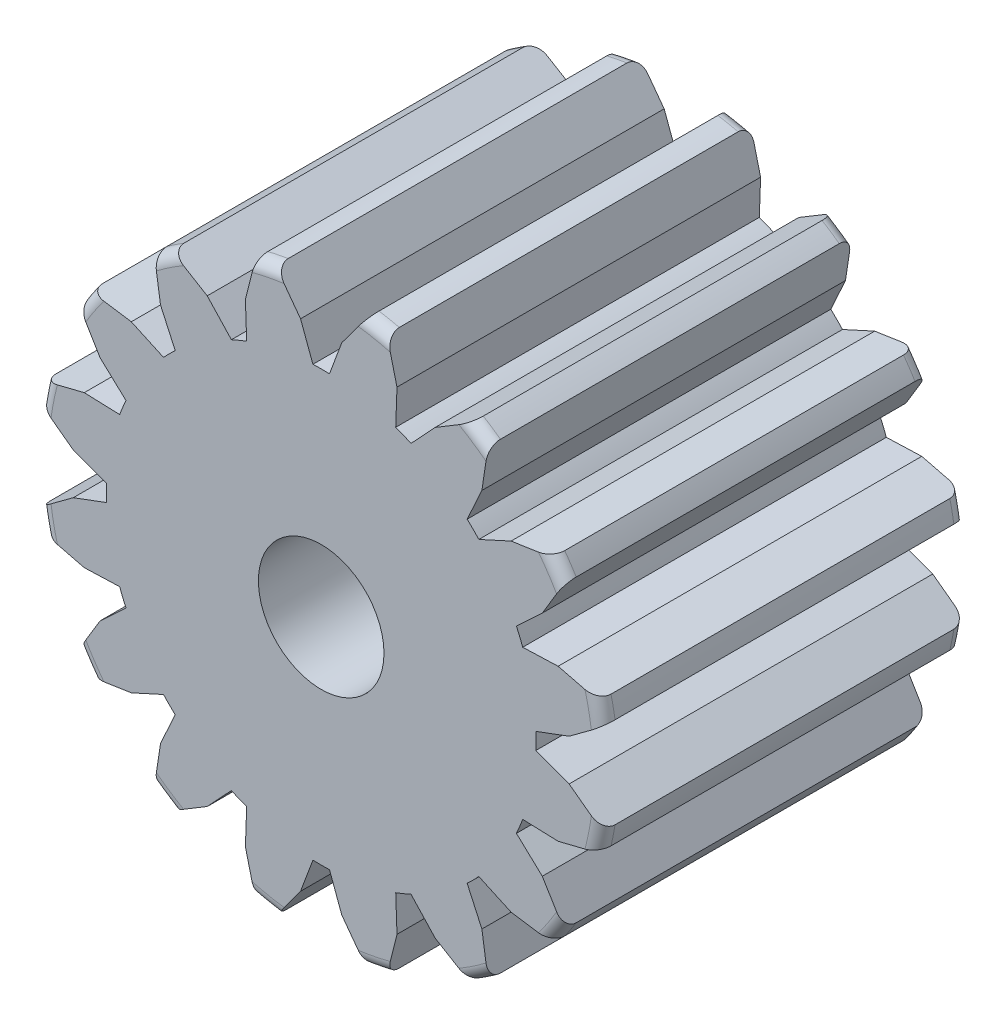
from build123d import *

# Parameters (mm, degrees)
CROQUIS1_R              = 3.45
SALIENTE_EXTRUIR1_DEPTH = 4.4
CORTAR_EXTRUIR1_DEPTH   = 4.4
REDONDEO1_R             = 0.15
MATRIZC1_COUNT          = 16
CROQUIS2_3_R            = 0.76
CORTAR_EXTRUIR2_DEPTH   = 4.4


with BuildPart() as part:
    # Croquis1 → Saliente-Extruir1 (new body)
    with BuildSketch(Plane.XY):
        Circle(CROQUIS1_R)
    extrude(amount=SALIENTE_EXTRUIR1_DEPTH)

    # Croquis2 → Cortar-Extruir1 (cut)
    with BuildSketch(Plane.XY.offset(4.4)):
        with BuildLine():
            Line((0.55, 3.405877273), (0.55, 3.7))
            Line((0.55, 3.7), (-0.55, 3.7))
            Line((-0.55, 3.7), (-0.55, 3.405877273))
            Line((-0.55, 3.405877273), (-0.25, 3))
            Line((-0.25, 3), (-0.1, 2.598076211))
            ThreePointArc((-0.1, 2.598076211), (0, 2.6), (0.1, 2.598076211))
            Line((0.1, 2.598076211), (0.25, 3))
            Line((0.25, 3), (0.55, 3.405877273))
        make_face()
    cortar_extruir1 = extrude(amount=-CORTAR_EXTRUIR1_DEPTH, mode=Mode.SUBTRACT)

    # Redondeo1
    redondeo1_edges = [part.edges().sort_by_distance(p)[0] for p in [
        (0, -3.45, 0),
        (0, -3.45, 4.4),
    ]]
    fillet(redondeo1_edges, radius=REDONDEO1_R)

    # MatrizC1: Cortar-Extruir1 ×16 about axis
    matrizc1_axis = Axis((0, 0, 0), (0, 0, 1))
    for i in range(1, MATRIZC1_COUNT):
        add(cortar_extruir1.rotate(matrizc1_axis, i * 360 / MATRIZC1_COUNT), mode=Mode.SUBTRACT)

    # Croquis2_3 → Cortar-Extruir2 (cut)
    with BuildSketch(Plane.XY.offset(4.4)):
        Circle(CROQUIS2_3_R)
    extrude(amount=-CORTAR_EXTRUIR2_DEPTH, mode=Mode.SUBTRACT)


solid = part.part
